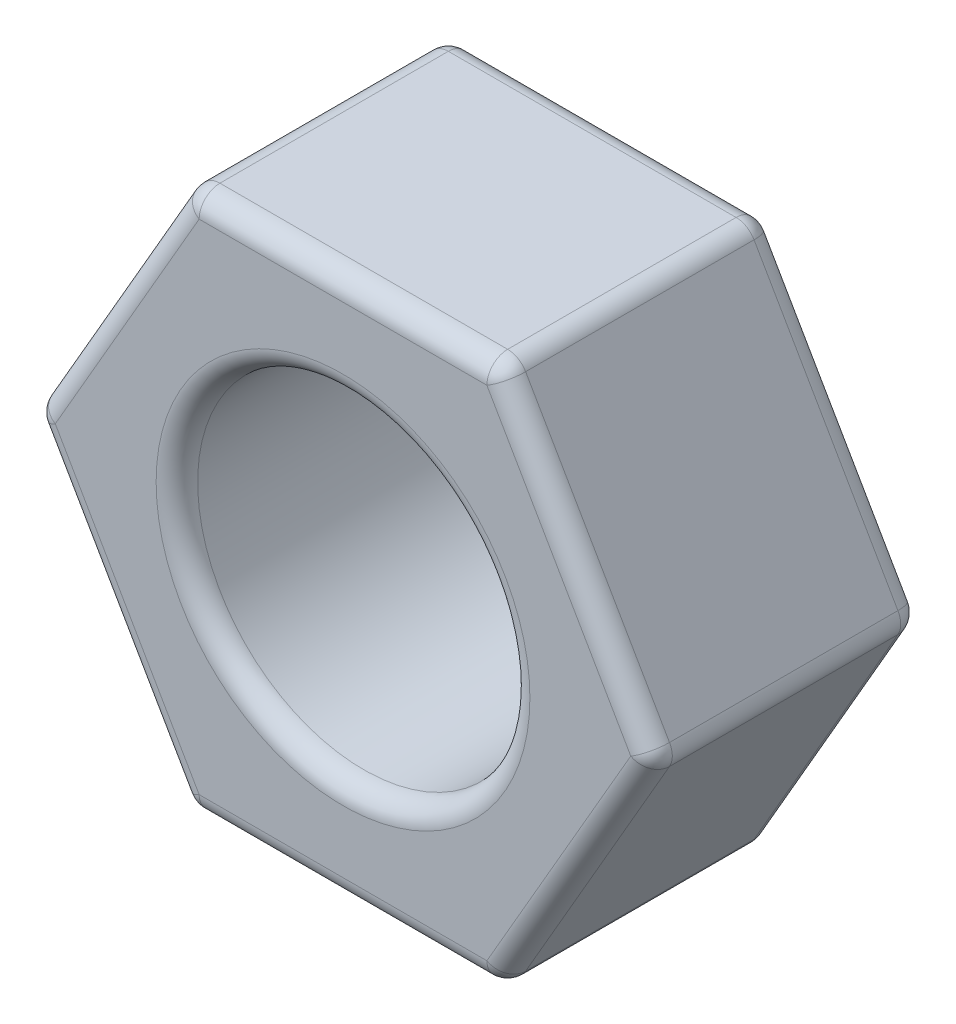
from build123d import *

# Parameters (mm, degrees)
BOSS_EXTRUDE1_DEPTH      = 6.5
M7_CLEARANCE_HOLE1_D     = 8
M7_CLEARANCE_HOLE1_DEPTH = 14
M7_CLEARANCE_HOLE1_TIP   = 2.403442476
FILLET1_R                = 0.5


with BuildPart() as part:
    # Sketch1 → Boss-Extrude1 (new body)
    with BuildSketch(Plane.XY):
        Polygon((-7.505553499, 0), (-3.75277675, -6.5), (3.75277675, -6.5), (7.505553499, 0), (3.75277675, 6.5), (-3.75277675, 6.5), align=None)
    extrude(amount=BOSS_EXTRUDE1_DEPTH)

    # M7 Clearance Hole1
    with Locations(Plane.XY.offset(6.5)):
        with Locations((0, 0)):
            Hole(M7_CLEARANCE_HOLE1_D / 2, depth=M7_CLEARANCE_HOLE1_DEPTH)
            with Locations((0, 0, -(M7_CLEARANCE_HOLE1_DEPTH + M7_CLEARANCE_HOLE1_TIP / 2))):  # 118° drill point
                Cone(0, M7_CLEARANCE_HOLE1_D / 2, M7_CLEARANCE_HOLE1_TIP, mode=Mode.SUBTRACT)

    # Fillet1
    fillet1_edges = [part.edges().sort_by_distance(p)[0] for p in [
        (0, -6.5, 6.5),
        (-3.75277675, 6.5, 3.25),
        (3.75277675, 6.5, 3.25),
        (7.505553499, 0, 3.25),
        (3.75277675, -6.5, 3.25),
        (-3.75277675, -6.5, 3.25),
        (-7.505553499, 0, 3.25),
        (5.629165125, -3.25, 6.5),
        (5.629165125, 3.25, 6.5),
        (0, 6.5, 6.5),
        (4, 0, 0),
        (4, 0, 6.5),
        (-5.629165125, 3.25, 6.5),
        (0, 6.5, 0),
        (5.629165125, 3.25, 0),
        (5.629165125, -3.25, 0),
        (-5.629165125, -3.25, 6.5),
        (0, -6.5, 0),
        (-5.629165125, -3.25, 0),
        (-5.629165125, 3.25, 0),
    ]]
    fillet(fillet1_edges, radius=FILLET1_R)


solid = part.part
